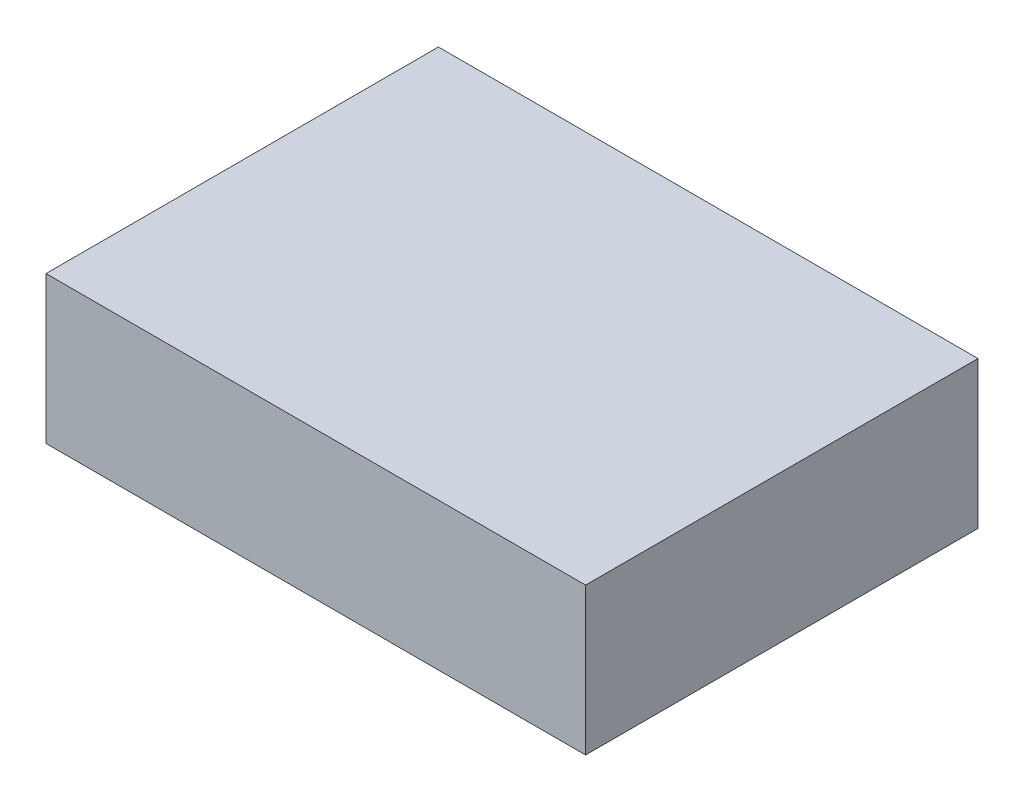
from build123d import *

# Parameters (mm, degrees)
SKETCH1_W           = 69.85
SKETCH1_H           = 50.8
BOSS_EXTRUDE1_DEPTH = 19.05


with BuildPart() as part:
    # Sketch1 → Boss-Extrude1 (new body)
    with BuildSketch(Plane(origin=(0, 0, 0), x_dir=(1, 0, 0), z_dir=(0, 1, 0))):
        with Locations((-1.398316062, -9.212435233)):
            Rectangle(SKETCH1_W, SKETCH1_H)
    extrude(amount=BOSS_EXTRUDE1_DEPTH)


solid = part.part
